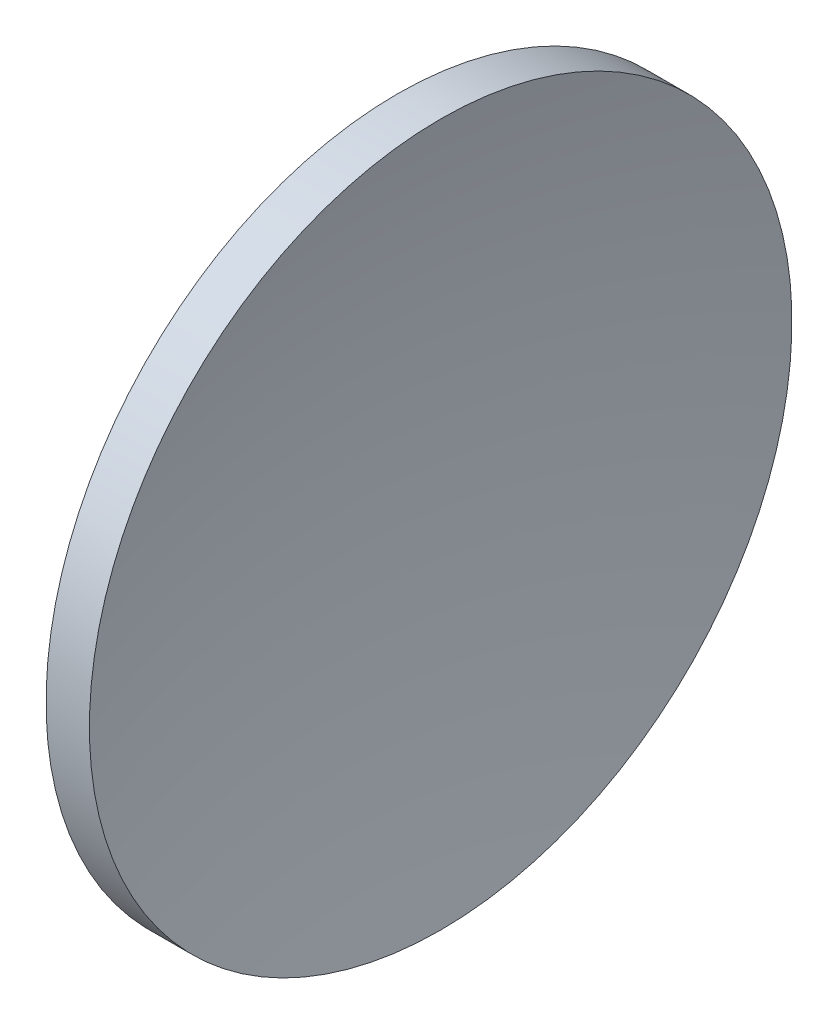
from build123d import *


with BuildPart() as part:
    # 草图1 → 旋转1 (revolve)
    with BuildSketch(Plane.XY):
        with BuildLine():
            Line((128.760487212, 84.241840471), (131.107081428, 84.241840471))
            ThreePointArc((131.107081428, 84.241840471), (129.420293896, 74.795731303), (128.855421316, 65.216840471))
            Line((128.855421316, 65.216840471), (122.855421316, 65.216840471))
            ThreePointArc((122.855421316, 65.216840471), (124.365627098, 75.177016527), (128.760487212, 84.241840471))
        make_face()
    revolve(axis=Axis((115.944491298, 65.216840471, 0), (1, 0, 0)))


solid = part.part
